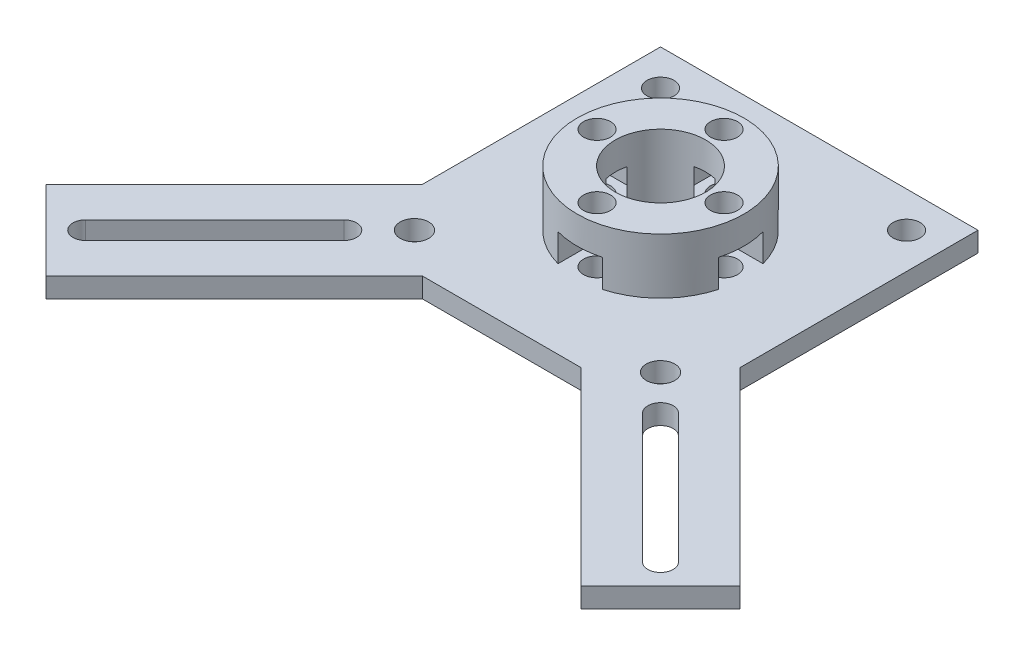
from build123d import *

# Parameters (mm, degrees)
SKETCH_1_R          = 1.7
SKETCH_1_R_2        = 1.8
SKETCH_1_R_3        = 5.7
EXTRUDE_1_DEPTH     = 2.5
SKETCH_2_R          = 10.5
EXTRUDE_2_DEPTH     = 7
SKETCH_4_R          = 1.7
CUT_EXTRUDE_1_DEPTH = 7
CUT_EXTRUDE_2_DEPTH = 3.5
SKETCH_6_R          = 5.7
CUT_EXTRUDE_3_DEPTH = 20


with BuildPart() as part:
    # 草图1 → 凸台-拉伸1 (new body)
    with BuildSketch(Plane(origin=(0, 0, 0), x_dir=(1, 0, 0), z_dir=(0, 1, 0))):
        Polygon((-10, -20), (10, -20), (33.844622395, -43.844622395), (43.844622395, -33.844622395), (20, -10), (20, 20), (-20, 20), (-20, -10), (-43.713203436, -33.713203436), (-33.713203436, -43.713203436), align=None)
        with Locations((-15.5, 15.5)):
            Circle(SKETCH_1_R, mode=Mode.SUBTRACT)
        with Locations((15.5, 15.5)):
            Circle(SKETCH_1_R, mode=Mode.SUBTRACT)
        with Locations((-15.5, -15.5)):
            Circle(SKETCH_1_R_2, mode=Mode.SUBTRACT)
        with Locations((15.5, -15.5)):
            Circle(SKETCH_1_R_2, mode=Mode.SUBTRACT)
        Circle(SKETCH_1_R_3, mode=Mode.SUBTRACT)
        with Locations((-8, 0)):
            Circle(SKETCH_1_R, mode=Mode.SUBTRACT)
        with Locations((0, 8)):
            Circle(SKETCH_1_R, mode=Mode.SUBTRACT)
        with Locations((8, 0)):
            Circle(SKETCH_1_R, mode=Mode.SUBTRACT)
        with Locations((0, -8)):
            Circle(SKETCH_1_R, mode=Mode.SUBTRACT)
        with BuildLine():
            Line((-18.818376618, -21.081118318), (-35.081832586, -37.344574285))
            ThreePointArc((-35.081832586, -37.344574285), (-37.344574285, -37.344574285), (-37.344574285, -35.081832586))
            Line((-37.344574285, -35.081832586), (-21.081118318, -18.818376618))
            ThreePointArc((-21.081118318, -18.818376618), (-18.818376618, -18.818376618), (-18.818376618, -21.081118318))
        make_face(mode=Mode.SUBTRACT)
        with BuildLine():
            Line((21.081118316, -18.818376616), (37.344574284, -35.081832584))
            ThreePointArc((37.344574284, -35.081832584), (37.344574284, -37.344574284), (35.081832584, -37.344574284))
            Line((35.081832584, -37.344574284), (18.818376616, -21.081118316))
            ThreePointArc((18.818376616, -21.081118316), (18.818376616, -18.818376616), (21.081118316, -18.818376616))
        make_face(mode=Mode.SUBTRACT)
    extrude(amount=EXTRUDE_1_DEPTH)

    # 草图2 → 凸台-拉伸2 (add)
    with BuildSketch(Plane(origin=(0, 2.5, 0), x_dir=(1, 0, 0), z_dir=(0, 1, 0))):
        Circle(SKETCH_2_R)
    extrude(amount=EXTRUDE_2_DEPTH)

    # 草图4 → 切除-拉伸1 (cut)
    with BuildSketch(Plane.XZ.offset(-2.5)):
        with Locations((0, -8)):
            Circle(SKETCH_4_R)
        with Locations((-8, 0)):
            Circle(SKETCH_4_R)
        with Locations((8, 0)):
            Circle(SKETCH_4_R)
        with Locations((0, 8)):
            Circle(SKETCH_4_R)
    extrude(amount=-CUT_EXTRUDE_1_DEPTH, mode=Mode.SUBTRACT)

    # 草图5 → 切除-拉伸2 (cut)
    with BuildSketch(Plane(origin=(0, 2.5, 0), x_dir=(1, 0, 0), z_dir=(0, 1, 0))):
        Polygon((-4.766838493, 0), (-6.383419246, 2.8), (-11.233161507, 2.8), (-11.233161507, -2.8), (-6.383419246, -2.8), align=None)
        Polygon((4.766838493, 0), (6.383419246, -2.8), (11.233161507, -2.8), (11.233161507, 2.8), (6.383419246, 2.8), align=None)
        Polygon((-2.8, 11.233161507), (-2.8, 6.383419246), (0, 4.766838493), (2.8, 6.383419246), (2.8, 11.233161507), align=None)
        Polygon((0, -4.766838493), (-2.8, -6.383419246), (-2.8, -11.233161507), (2.8, -11.233161507), (2.8, -6.383419246), align=None)
    extrude(amount=CUT_EXTRUDE_2_DEPTH, mode=Mode.SUBTRACT)

    # 草图6 → 切除-拉伸3 (cut)
    with BuildSketch(Plane.XZ.offset(-2.5)):
        Circle(SKETCH_6_R)
    extrude(amount=-CUT_EXTRUDE_3_DEPTH, mode=Mode.SUBTRACT)


solid = part.part
